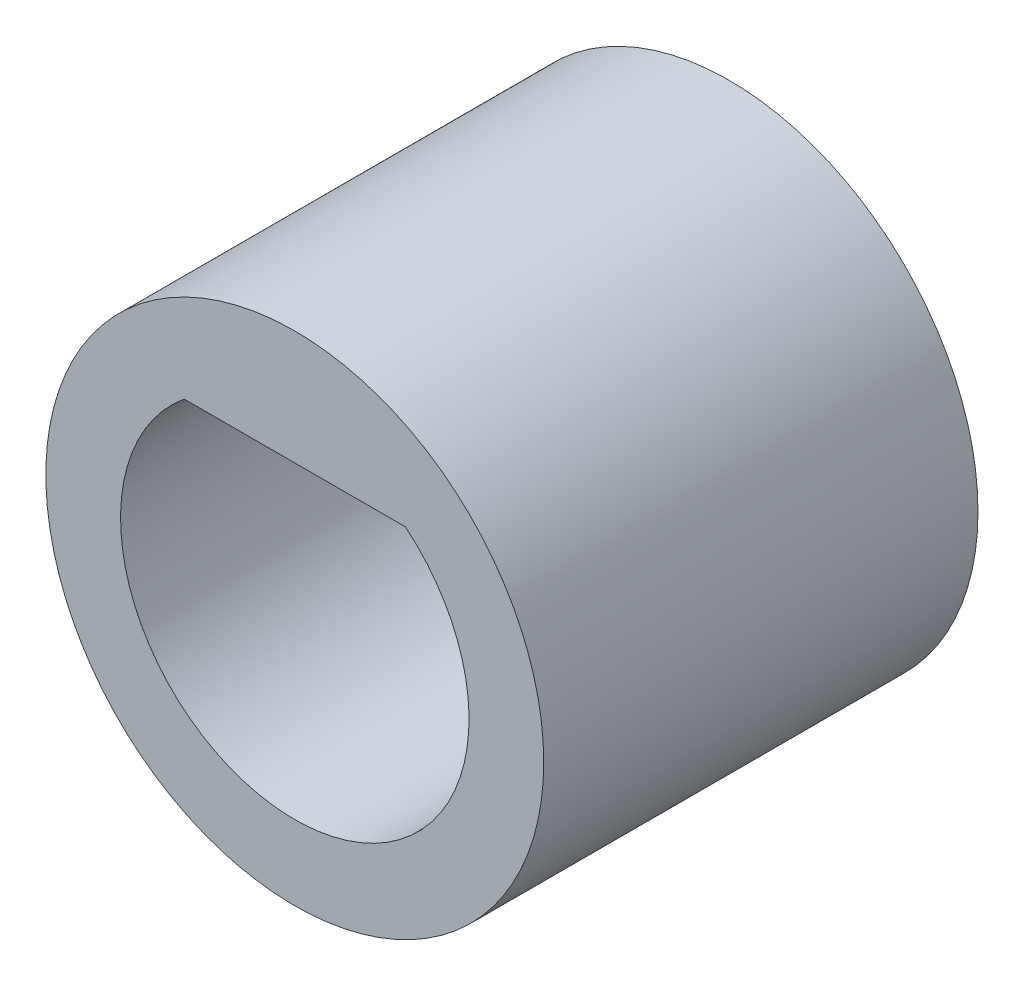
from build123d import *

# Parameters (mm, degrees)
SKETCH1_R           = 5.715
BOSS_EXTRUDE1_DEPTH = 9.968992
SKETCH2_R           = 2.3876
CUT_EXTRUDE1_DEPTH  = 10.968992
SKETCH3_R           = 4
CUT_EXTRUDE2_DEPTH  = 6.35
BOSS_EXTRUDE2_DEPTH = 6.35


with BuildPart() as part:
    # Sketch1 → Boss-Extrude1 (new body)
    with BuildSketch(Plane.XY):
        Circle(SKETCH1_R)
    extrude(amount=BOSS_EXTRUDE1_DEPTH)

    # Sketch2 → Cut-Extrude1 (cut, through all)
    with BuildSketch(Plane(origin=(0, 0, 0), x_dir=(-1, 0, 0), z_dir=(0, 0, -1))):
        Circle(SKETCH2_R)
    extrude(amount=-CUT_EXTRUDE1_DEPTH, mode=Mode.SUBTRACT)

    # Sketch3 → Cut-Extrude2 (cut)
    with BuildSketch(Plane.XY.offset(9.968992)):
        Circle(SKETCH3_R)
    extrude(amount=-CUT_EXTRUDE2_DEPTH, mode=Mode.SUBTRACT)

    # Sketch4 → Boss-Extrude2 (add)
    with BuildSketch(Plane.XY.offset(9.968992)):
        with BuildLine():
            Line((2.54, 3.090048543), (-2.54, 3.090048543))
            ThreePointArc((-2.54, 3.090048543), (0, 4), (2.54, 3.090048543))
        make_face()
    extrude(amount=-BOSS_EXTRUDE2_DEPTH)


solid = part.part
